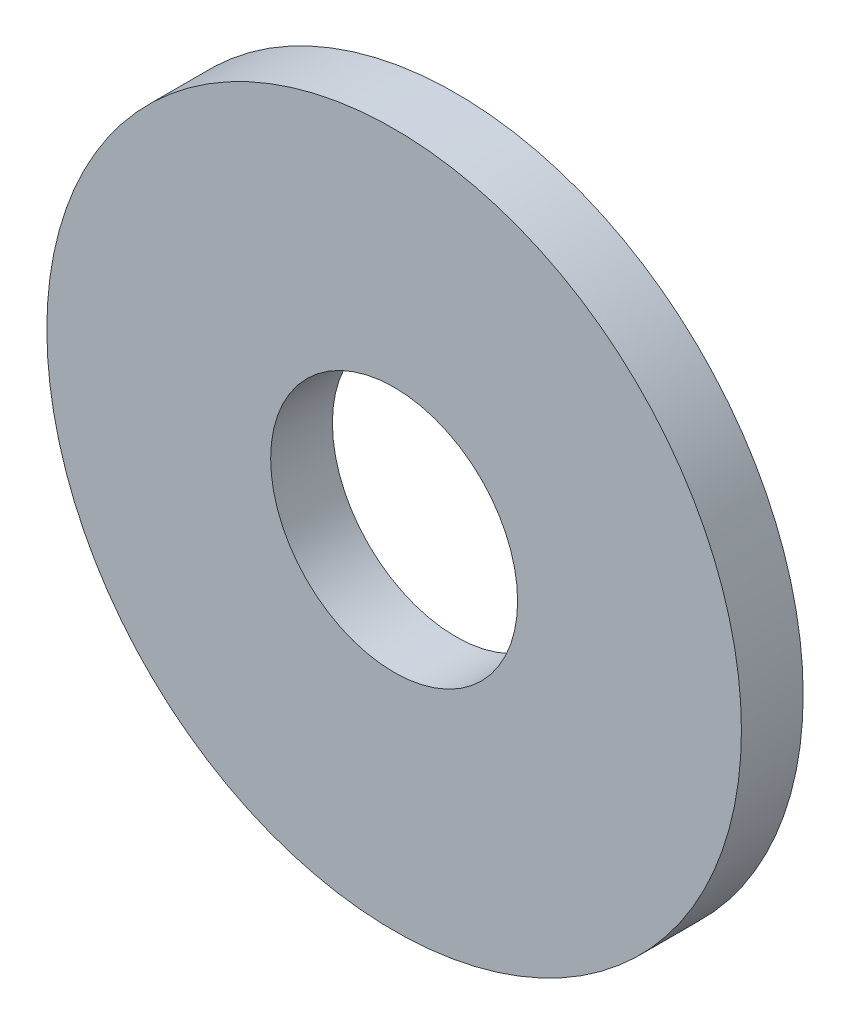
from build123d import *

# Parameters (mm, degrees)
SKETCH_1_R      = 4.5
SKETCH_1_R_2    = 1.6
EXTRUDE_1_DEPTH = 0.8


with BuildPart() as part:
    # 草图1 → 凸台-拉伸1 (new body)
    with BuildSketch(Plane.XY):
        Circle(SKETCH_1_R)
        Circle(SKETCH_1_R_2, mode=Mode.SUBTRACT)
    extrude(amount=EXTRUDE_1_DEPTH)


solid = part.part
